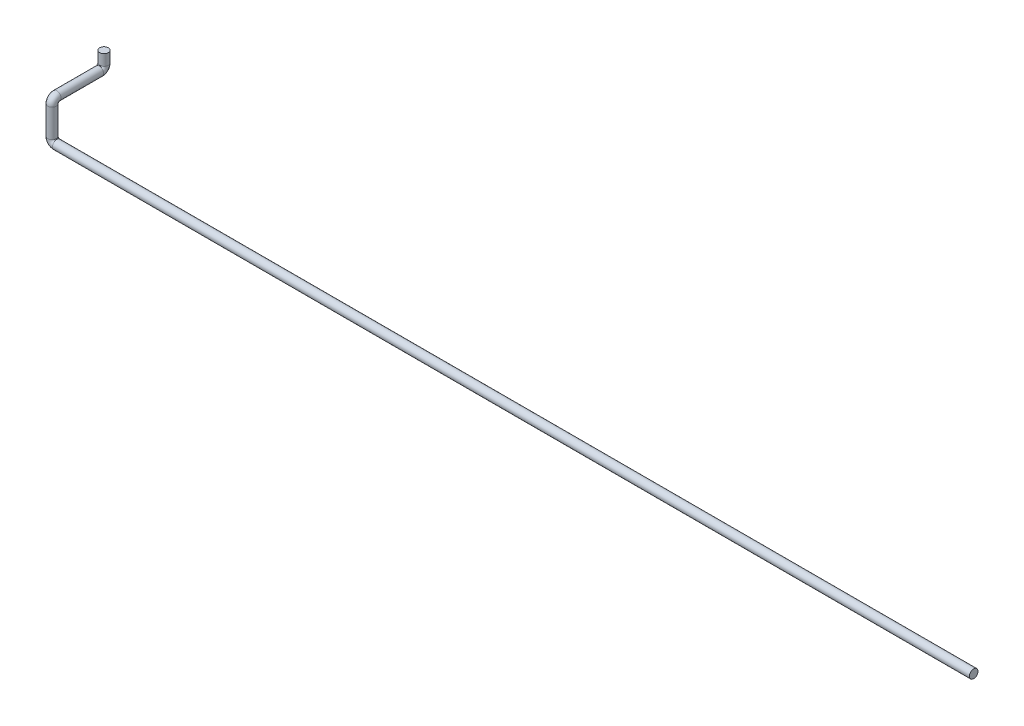
from build123d import *

# Parameters (mm, degrees)
CROQUIS1_R = 13.7


with BuildPart() as part:
    # Barrer1: sweep along a curve in space
    with BuildLine() as barrer1_path:
        Line((0, 0, 0), (-2930, 0, 0))
        ThreePointArc((-2930, 0, 0), (-2940.606601718, 4.393398282, 0), (-2945, 15, 0))
        Line((-2945, 15, 0), (-2945, 105, 0))
        ThreePointArc((-2945, 105, 0), (-2945, 115.606601718, -4.393398282), (-2945, 120, -15))
        Line((-2945, 120, -15), (-2945, 120, -151))
        ThreePointArc((-2945, 120, -151), (-2945, 124.393398282, -161.606601718), (-2945, 135, -166))
        Line((-2945, 135, -166), (-2945, 170, -166))
    # Croquis1 → Barrer1 (sweep)
    with BuildSketch(Plane(origin=(0, 0, 0), x_dir=(0, 0, -1), z_dir=(1, 0, 0))):
        Circle(CROQUIS1_R)
    sweep(path=barrer1_path.line)


solid = part.part
